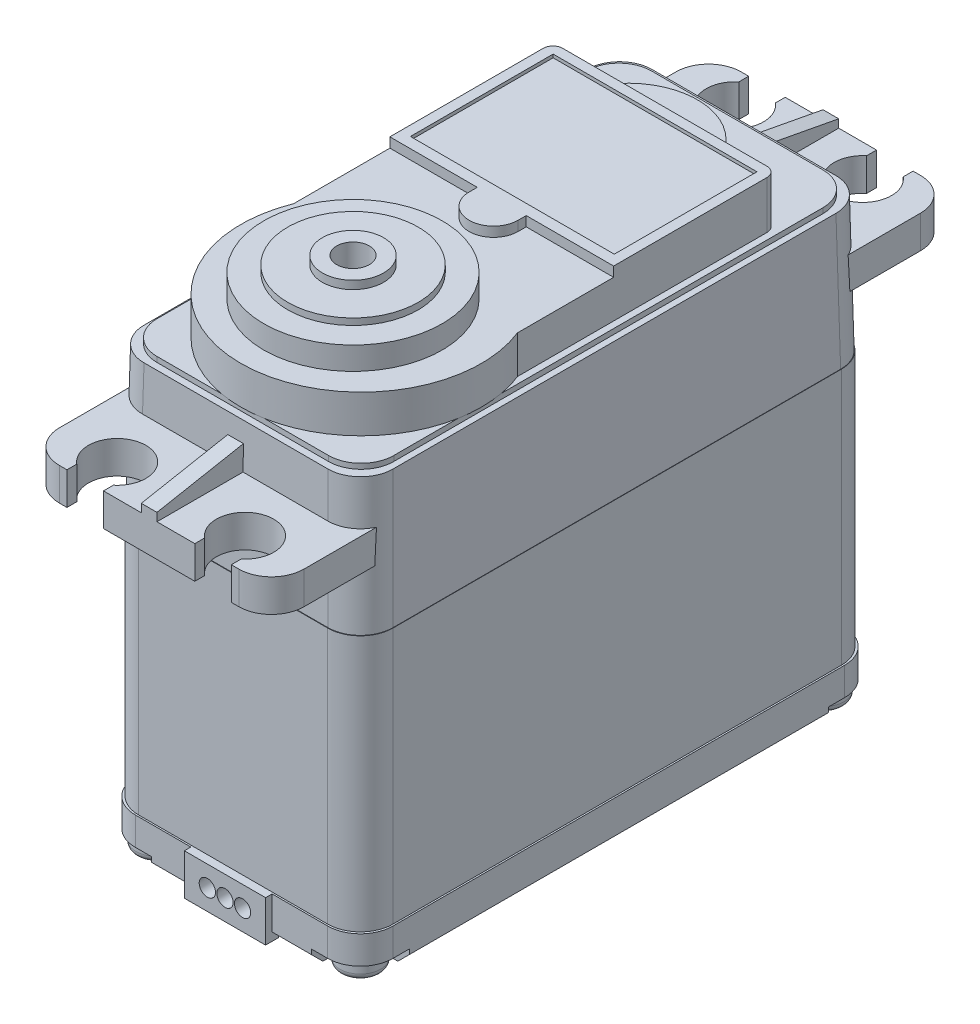
from build123d import *

# Parameters (mm, degrees)
SKETCH1_W            = 19.812
SKETCH1_H            = 40.005
EXTRUDE1_DEPTH       = 19.9644
SKETCH2_W            = 20.066
SKETCH2_H            = 40.259
EXTRUDE2_DEPTH       = 3.4544
SKETCH3_W            = 19.7612
SKETCH3_H            = 39.9288
EXTRUDE3_DEPTH       = 10.5156
EXTRUDE3_TAPER       = 1
SKETCH4_W            = 18.4404
SKETCH4_H            = 38.5064
EXTRUDE4_DEPTH       = 0.4064
FILLET1_R            = 2.54
FILLET2_R            = 2.54
FILLET3_R            = 2.54
FILLET4_R            = 2.54
EXTRUDE5_DEPTH       = 1.27
SKETCH6_R            = 1.5875
EXTRUDE7_DEPTH       = 1.27
FILLET5_R            = 0.508
SKETCH7_W            = 0.362371406
SKETCH7_H            = 2.12837214
EXTRUDE8_DEPTH       = 0.508
SKETCH8_W            = 2.12837214
SKETCH8_H            = 0.362371406
EXTRUDE9_DEPTH       = 0.508
SKETCH9_W            = 19.05
SKETCH9_H            = 53.086
EXTRUDE10_DEPTH      = 2.54
SKETCH10_R           = 2.2352
EXTRUDE11_DEPTH      = 31.48
SKETCH11_W           = 2.8448
SKETCH11_H           = 6.35
EXTRUDE12_DEPTH      = 31.48
FILLET6_R            = 2.54
SKETCH12_R           = 0.9525
EXTRUDE13_DEPTH      = 0.635
FILLET7_R            = 0.254
CHAMFER1_SIZE        = 0.889
EXTRUDE14_DEPTH      = 2.9464
EXTRUDE15_DEPTH      = 0.762
SKETCH15_W           = 15.875
SKETCH15_H           = 11.1125
EXTRUDE16_DEPTH      = 0.254
FILLET8_R            = 0.762
SKETCH16_R           = 6.9469
EXTRUDE17_DEPTH      = 1.778
SKETCH17_R           = 5.08
EXTRUDE18_DEPTH      = 0.508
SKETCH18_R           = 2.38125
EXTRUDE19_DEPTH      = 0.635
SKETCH19_R           = 1.27
EXTRUDE20_DEPTH      = 3.175
SKETCH20_W           = 6.3246
SKETCH20_H           = 3.2004
EXTRUDE21_DEPTH      = 0.508
EXTRUDE21_DEPTH_BACK = 0.508
SKETCH21_R           = 0.635
EXTRUDE22_DEPTH      = 2.54
EXTRUDE23_DEPTH      = 0.6096


with BuildPart() as part:
    # Sketch1 → Extrude1 (new body)
    with BuildSketch(Plane(origin=(0, 0, 0), x_dir=(1, 0, 0), z_dir=(0, 1, 0))):
        Rectangle(SKETCH1_W, SKETCH1_H)
    extrude(amount=EXTRUDE1_DEPTH)

    # Sketch2 → Extrude2 (add)
    with BuildSketch(Plane.XZ):
        Rectangle(SKETCH2_W, SKETCH2_H)
    extrude(amount=EXTRUDE2_DEPTH)

    # Sketch3 → Extrude3 (add)
    with BuildSketch(Plane(origin=(0, 19.9644, 0), x_dir=(1, 0, 0), z_dir=(0, 1, 0))):
        Rectangle(SKETCH3_W, SKETCH3_H)
    extrude(amount=EXTRUDE3_DEPTH, taper=EXTRUDE3_TAPER)

    # Sketch4 → Extrude4 (add)
    with BuildSketch(Plane(origin=(0, 30.48, 0), x_dir=(1, 0, 0), z_dir=(0, 1, 0))):
        Rectangle(SKETCH4_W, SKETCH4_H)
    extrude(amount=EXTRUDE4_DEPTH)

    # Fillet1
    fillet1_edges = [part.edges().sort_by_distance(p)[0] for p in [
        (9.2202, 30.6832, 19.2532),
        (9.2202, 30.6832, -19.2532),
        (-9.2202, 30.6832, -19.2532),
        (-9.2202, 30.6832, 19.2532),
    ]]
    fillet(fillet1_edges, radius=FILLET1_R)

    # Fillet2
    fillet2_edges = [part.edges().sort_by_distance(p)[0] for p in [
        (9.78882476, 25.2222, 19.87262476),
        (9.78882476, 25.2222, -19.87262476),
        (-9.78882476, 25.2222, -19.87262476),
        (-9.78882476, 25.2222, 19.87262476),
    ]]
    fillet(fillet2_edges, radius=FILLET2_R)

    # Fillet3
    fillet3_edges = [part.edges().sort_by_distance(p)[0] for p in [
        (9.906, 9.9822, 20.0025),
        (-9.906, 9.9822, 20.0025),
        (-9.906, 9.9822, -20.0025),
        (9.906, 9.9822, -20.0025),
    ]]
    fillet(fillet3_edges, radius=FILLET3_R)

    # Fillet4
    fillet4_edges = [part.edges().sort_by_distance(p)[0] for p in [
        (10.033, -1.7272, -20.1295),
        (10.033, -1.7272, 20.1295),
        (-10.033, -1.7272, 20.1295),
        (-10.033, -1.7272, -20.1295),
    ]]
    fillet(fillet4_edges, radius=FILLET4_R)

    # Sketch5 → Extrude5 (cut)
    with BuildSketch(Plane.XZ.offset(3.4544)):
        with BuildLine():
            Line((-6.223, 20.1295), (-6.223, 16.3195))
            Line((-6.223, 16.3195), (-10.033, 16.3195))
            Line((-10.033, 16.3195), (-10.033, 17.5895))
            ThreePointArc((-10.033, 17.5895), (-9.289051224, 19.385551224), (-7.493, 20.1295))
            Line((-7.493, 20.1295), (-6.223, 20.1295))
        make_face()
        with BuildLine():
            Line((6.223, 20.1295), (6.223, 16.3195))
            Line((6.223, 16.3195), (10.033, 16.3195))
            Line((10.033, 16.3195), (10.033, 17.5895))
            ThreePointArc((10.033, 17.5895), (9.289051224, 19.385551224), (7.493, 20.1295))
            Line((7.493, 20.1295), (6.223, 20.1295))
        make_face()
        with BuildLine():
            Line((-10.033, -16.3195), (-6.223, -16.3195))
            Line((-6.223, -16.3195), (-6.223, -20.1295))
            Line((-6.223, -20.1295), (-7.493, -20.1295))
            ThreePointArc((-7.493, -20.1295), (-9.289051224, -19.385551224), (-10.033, -17.5895))
            Line((-10.033, -17.5895), (-10.033, -16.3195))
        make_face()
        with BuildLine():
            Line((6.223, -20.1295), (6.223, -16.3195))
            Line((6.223, -16.3195), (10.033, -16.3195))
            Line((10.033, -16.3195), (10.033, -17.5895))
            ThreePointArc((10.033, -17.5895), (9.289051224, -19.385551224), (7.493, -20.1295))
            Line((7.493, -20.1295), (6.223, -20.1295))
        make_face()
    extrude(amount=-EXTRUDE5_DEPTH, mode=Mode.SUBTRACT)

    # Sketch6 → Extrude7 (add)
    with BuildSketch(Plane.XZ.offset(2.1844)):
        with Locations((-7.9375, 18.034)):
            Circle(SKETCH6_R)
        with Locations((7.9375, 18.034)):
            Circle(SKETCH6_R)
        with Locations((7.9375, -18.034)):
            Circle(SKETCH6_R)
        with Locations((-7.9375, -18.034)):
            Circle(SKETCH6_R)
    extrude(amount=EXTRUDE7_DEPTH)

    # Fillet5
    fillet5_edges = [part.edges().sort_by_distance(p)[0] for p in [
        (-9.525, -3.4544, 18.034),
        (6.35, -3.4544, 18.034),
        (6.35, -3.4544, -18.034),
        (-9.525, -3.4544, -18.034),
    ]]
    fillet(fillet5_edges, radius=FILLET5_R)

    # Sketch7 → Extrude8 (cut)
    with BuildSketch(Plane.XZ.offset(3.4544)):
        with Locations((-7.9375, -18.034)):
            Rectangle(SKETCH7_W, SKETCH7_H)
        with Locations((7.9375, -18.034)):
            Rectangle(SKETCH7_W, SKETCH7_H)
        with Locations((-7.9375, 18.034)):
            Rectangle(SKETCH7_W, SKETCH7_H)
        with Locations((7.9375, 18.034)):
            Rectangle(SKETCH7_W, SKETCH7_H)
    extrude(amount=-EXTRUDE8_DEPTH, mode=Mode.SUBTRACT)

    # Sketch8 → Extrude9 (cut)
    with BuildSketch(Plane.XZ.offset(3.4544)):
        with Locations((-7.9375, 18.034)):
            Rectangle(SKETCH8_W, SKETCH8_H)
        with Locations((7.9375, 18.034)):
            Rectangle(SKETCH8_W, SKETCH8_H)
        with Locations((-7.9375, -18.034)):
            Rectangle(SKETCH8_W, SKETCH8_H)
        with Locations((7.9375, -18.034)):
            Rectangle(SKETCH8_W, SKETCH8_H)
    extrude(amount=-EXTRUDE9_DEPTH, mode=Mode.SUBTRACT)

    # Sketch9 → Extrude10 (add)
    with BuildSketch(Plane.XZ.offset(-27.0256)):
        Rectangle(SKETCH9_W, SKETCH9_H)
    extrude(amount=EXTRUDE10_DEPTH)

    # Sketch10 → Extrude11 (cut, through all)
    with BuildSketch(Plane(origin=(0, 27.0256, 0), x_dir=(1, 0, 0), z_dir=(0, 1, 0))):
        with Locations((4.9784, 24.0538)):
            Circle(SKETCH10_R)
        with Locations((-4.9784, 24.0538)):
            Circle(SKETCH10_R)
        with Locations((4.9784, -24.0538)):
            Circle(SKETCH10_R)
        with Locations((-4.9784, -24.0538)):
            Circle(SKETCH10_R)
    extrude(amount=-EXTRUDE11_DEPTH, mode=Mode.SUBTRACT)

    # Sketch11 → Extrude12 (cut, through all)
    with BuildSketch(Plane(origin=(0, 27.0256, 0), x_dir=(1, 0, 0), z_dir=(0, 1, 0))):
        with Locations((-4.9784, 27.2288)):
            Rectangle(SKETCH11_W, SKETCH11_H)
        with Locations((4.9784, 27.2288)):
            Rectangle(SKETCH11_W, SKETCH11_H)
        with Locations((-4.9784, -27.2288)):
            Rectangle(SKETCH11_W, SKETCH11_H)
        with Locations((4.9784, -27.2288)):
            Rectangle(SKETCH11_W, SKETCH11_H)
    extrude(amount=-EXTRUDE12_DEPTH, mode=Mode.SUBTRACT)

    # Fillet6
    fillet6_edges = [part.edges().sort_by_distance(p)[0] for p in [
        (-9.525, 25.7556, 26.543),
        (-9.525, 25.7556, -26.543),
        (9.525, 25.7556, -26.543),
        (9.525, 25.7556, 26.543),
    ]]
    fillet(fillet6_edges, radius=FILLET6_R)

    # Sketch12 → Extrude13 (cut)
    with BuildSketch(Plane.XZ.offset(3.4544)):
        Circle(SKETCH12_R)
    extrude(amount=-EXTRUDE13_DEPTH, mode=Mode.SUBTRACT)

    # Fillet7
    fillet7_edges = [part.edges().sort_by_distance(p)[0] for p in [
        (-0.9525, -2.8194, 0),
    ]]
    fillet(fillet7_edges, radius=FILLET7_R)

    # Chamfer1
    chamfer1_edges = [part.edges().sort_by_distance(p)[0] for p in [
        (-10.033, -3.4544, 0),
        (0, -3.4544, 20.1295),
        (0, -3.4544, -20.1295),
        (10.033, -3.4544, 0),
    ]]
    chamfer(chamfer1_edges, length=CHAMFER1_SIZE)

    # Sketch13 → Extrude14 (add)
    with BuildSketch(Plane(origin=(0, 30.8864, 0), x_dir=(1, 0, 0), z_dir=(0, 1, 0))):
        with BuildLine():
            Line((-8.7122, 13.6144), (-4.572, 13.6144))
            ThreePointArc((-4.572, 13.6144), (0, 16.1544), (4.572, 13.6144))
            Line((4.572, 13.6144), (8.7122, 13.6144))
            Line((8.7122, 13.6144), (8.7122, -6.577106205))
            ThreePointArc((8.7122, -6.577106205), (0, -19.4056), (-8.7122, -6.577106205))
            Line((-8.7122, -6.577106205), (-8.7122, 13.6144))
        make_face()
    extrude(amount=EXTRUDE14_DEPTH)

    # Sketch14 → Extrude15 (add)
    with BuildSketch(Plane(origin=(0, 33.8328, 0), x_dir=(1, 0, 0), z_dir=(0, 1, 0))):
        with BuildLine():
            Line((-8.7122, 13.6144), (8.7122, 13.6144))
            Line((8.7122, 13.6144), (8.7122, 0.9144))
            Line((8.7122, 0.9144), (1.905, 0.9144))
            Line((1.905, 0.9144), (1.905, 0.2794))
            ThreePointArc((1.905, 0.2794), (0, -1.6256), (-1.905, 0.2794))
            Line((-1.905, 0.2794), (-1.905, 0.9144))
            Line((-1.905, 0.9144), (-8.7122, 0.9144))
            Line((-8.7122, 0.9144), (-8.7122, 13.6144))
        make_face()
    extrude(amount=EXTRUDE15_DEPTH)

    # Sketch15 → Extrude16 (cut)
    with BuildSketch(Plane(origin=(0, 34.5948, 0), x_dir=(1, 0, 0), z_dir=(0, 1, 0))):
        with Locations((0, 7.29615)):
            Rectangle(SKETCH15_W, SKETCH15_H)
    extrude(amount=-EXTRUDE16_DEPTH, mode=Mode.SUBTRACT)

    # Fillet8
    fillet8_edges = [part.edges().sort_by_distance(p)[0] for p in [
        (-8.7122, 32.7406, -13.6144),
        (8.7122, 32.7406, -13.6144),
    ]]
    fillet(fillet8_edges, radius=FILLET8_R)

    # Sketch16 → Extrude17 (add)
    with BuildSketch(Plane(origin=(0, 33.8328, 0), x_dir=(1, 0, 0), z_dir=(0, 1, 0))):
        with Locations((0, -10.668)):
            Circle(SKETCH16_R)
    extrude(amount=EXTRUDE17_DEPTH)

    # Sketch17 → Extrude18 (add)
    with BuildSketch(Plane(origin=(0, 35.6108, 0), x_dir=(1, 0, 0), z_dir=(0, 1, 0))):
        with Locations((0, -10.668)):
            Circle(SKETCH17_R)
    extrude(amount=EXTRUDE18_DEPTH)

    # Sketch18 → Extrude19 (add)
    with BuildSketch(Plane(origin=(0, 36.1188, 0), x_dir=(1, 0, 0), z_dir=(0, 1, 0))):
        with Locations((0, -10.668)):
            Circle(SKETCH18_R)
    extrude(amount=EXTRUDE19_DEPTH)

    # Sketch19 → Extrude20 (cut)
    with BuildSketch(Plane(origin=(0, 36.7538, 0), x_dir=(1, 0, 0), z_dir=(0, 1, 0))):
        with Locations((0, -10.668)):
            Circle(SKETCH19_R)
    extrude(amount=-EXTRUDE20_DEPTH, mode=Mode.SUBTRACT)

    # Sketch20 → Extrude21 (add, two sides)
    with BuildSketch(Plane.XY.offset(20.1295)) as extrude21_sk:
        with Locations((0, -1.6002)):
            Rectangle(SKETCH20_W, SKETCH20_H)
    extrude(amount=EXTRUDE21_DEPTH)
    extrude(extrude21_sk.sketch, amount=-EXTRUDE21_DEPTH_BACK)

    # Sketch21 → Extrude22 (cut)
    with BuildSketch(Plane.XY.offset(20.6375)):
        with Locations((0, -1.6002)):
            Circle(SKETCH21_R)
        with Locations((1.3716, -1.6002)):
            Circle(SKETCH21_R)
        with Locations((-1.3716, -1.6002)):
            Circle(SKETCH21_R)
    extrude(amount=-EXTRUDE22_DEPTH, mode=Mode.SUBTRACT)

    # Sketch22 → Extrude23 (add, symmetric)
    with BuildSketch(Plane(origin=(0, 0, 0), x_dir=(0, 0, -1), z_dir=(1, 0, 0))):
        Polygon((-19.807894397, 28.9306), (-26.543, 27.6606), (-26.543, 27.0256), (-19.841146296, 27.0256), align=None)
        Polygon((19.841146296, 27.0256), (26.543, 27.0256), (26.543, 27.6606), (19.807894397, 28.9306), align=None)
    extrude(amount=EXTRUDE23_DEPTH, both=True)


solid = part.part
